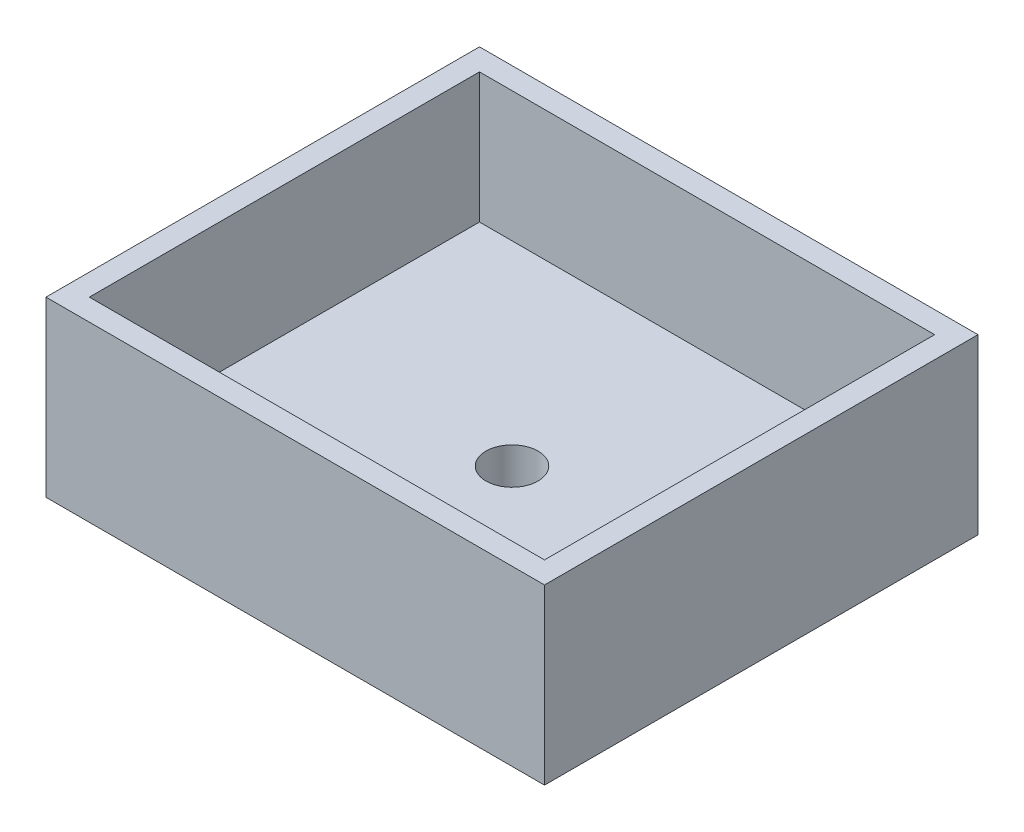
from build123d import *

# Parameters (mm, degrees)
SKETCH2_W           = 10.5
SKETCH2_H           = 9
BOSS_EXTRUDE2_DEPTH = 1
SKETCH2_3_W         = 11.5
SKETCH2_3_H         = 10
SKETCH2_3_W_2       = 10.5
SKETCH2_3_H_2       = 9
BOSS_EXTRUDE3_DEPTH = 4
SKETCH3_R           = 0.6
CUT_EXTRUDE1_DEPTH  = 10


with BuildPart() as part:
    # Sketch2 → Boss-Extrude2 (new body)
    with BuildSketch(Plane(origin=(0, 0, 0), x_dir=(1, 0, 0), z_dir=(0, 1, 0))):
        with Locations((5.75, 5)):
            Rectangle(SKETCH2_W, SKETCH2_H)
    extrude(amount=BOSS_EXTRUDE2_DEPTH)

    # Sketch2_3 → Boss-Extrude3 (add)
    with BuildSketch(Plane(origin=(0, 0, 0), x_dir=(1, 0, 0), z_dir=(0, 1, 0))):
        with Locations((5.75, 5)):
            Rectangle(SKETCH2_3_W, SKETCH2_3_H)
        with Locations((5.75, 5)):
            Rectangle(SKETCH2_3_W_2, SKETCH2_3_H_2, mode=Mode.SUBTRACT)
    extrude(amount=BOSS_EXTRUDE3_DEPTH)

    # Sketch3 → Cut-Extrude1 (cut)
    with BuildSketch(Plane(origin=(0, 1, 0), x_dir=(1, 0, 0), z_dir=(0, 1, 0))):
        with Locations((5.75, 5)):
            Circle(SKETCH3_R)
    extrude(amount=-CUT_EXTRUDE1_DEPTH, mode=Mode.SUBTRACT)


solid = part.part
